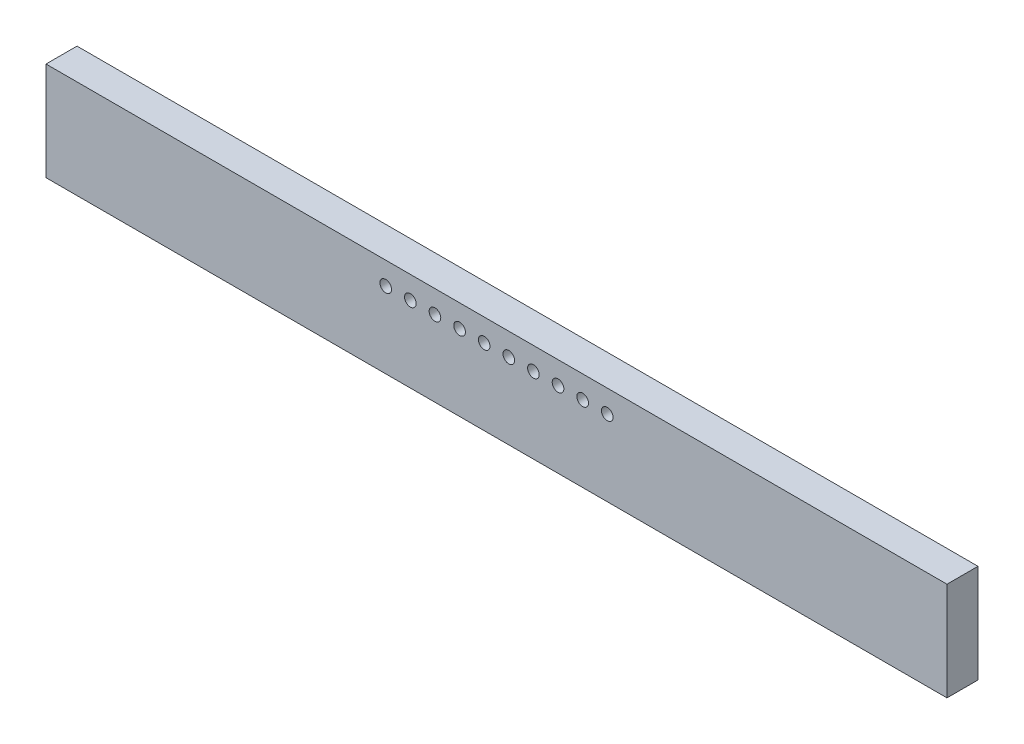
from build123d import *

# Parameters (mm, degrees)
SKETCH1_W           = 46.482
SKETCH1_H           = 5.08
BOSS_EXTRUDE1_DEPTH = 1.6
SKETCH2_R           = 0.3
CUT_EXTRUDE1_DEPTH  = 2.6


with BuildPart() as part:
    # Sketch1 → Boss-Extrude1 (new body)
    with BuildSketch(Plane.XY):
        Rectangle(SKETCH1_W, SKETCH1_H)
    extrude(amount=BOSS_EXTRUDE1_DEPTH)

    # Sketch2 → Cut-Extrude1 (cut, through all)
    with BuildSketch(Plane.XY.offset(1.6)):
        with Locations((-5.715, 1.38)):
            Circle(SKETCH2_R)
        with Locations((-4.445, 1.38)):
            Circle(SKETCH2_R)
        with Locations((-3.175, 1.38)):
            Circle(SKETCH2_R)
        with Locations((-1.905, 1.38)):
            Circle(SKETCH2_R)
        with Locations((-0.635, 1.38)):
            Circle(SKETCH2_R)
        with Locations((0.635, 1.38)):
            Circle(SKETCH2_R)
        with Locations((1.905, 1.38)):
            Circle(SKETCH2_R)
        with Locations((3.175, 1.38)):
            Circle(SKETCH2_R)
        with Locations((4.445, 1.38)):
            Circle(SKETCH2_R)
        with Locations((5.715, 1.38)):
            Circle(SKETCH2_R)
    extrude(amount=-CUT_EXTRUDE1_DEPTH, mode=Mode.SUBTRACT)


solid = part.part
